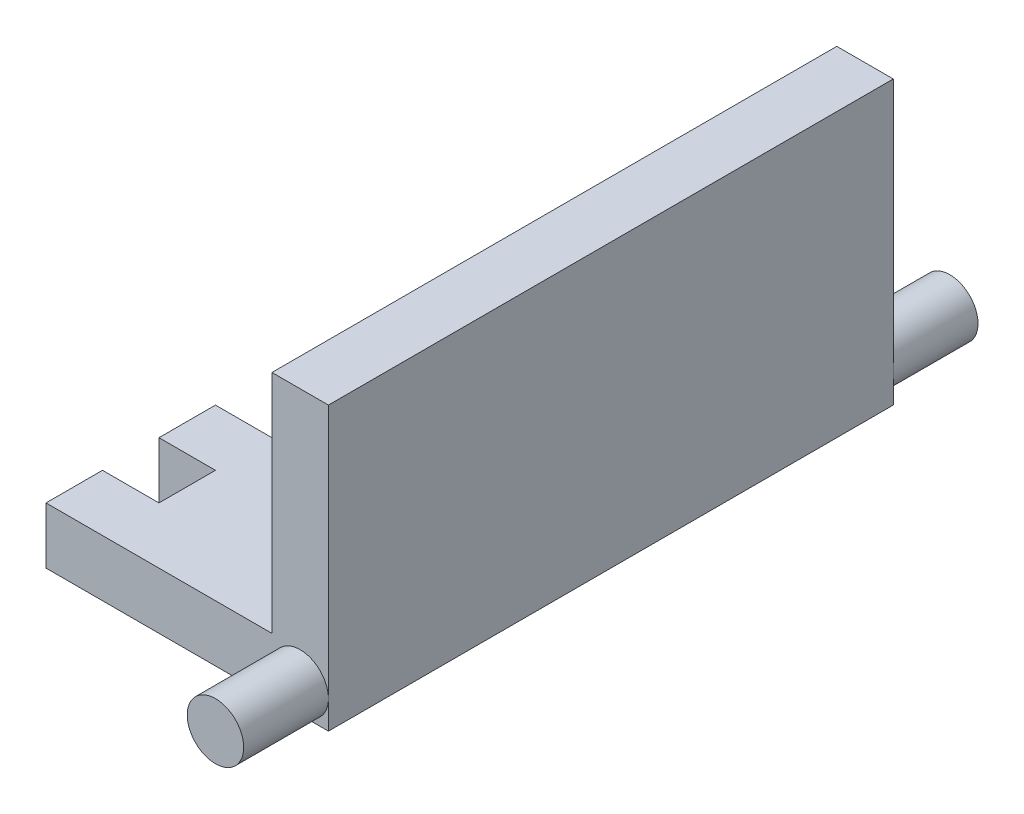
from build123d import *

# Parameters (mm, degrees)
ESQUISSE1_W                = 50
ESQUISSE1_H                = 10
BOSS_EXTRU_1_DEPTH         = 100
ESQUISSE2_R                = 5
BOSS_EXTRU_2_DEPTH         = 15
ESQUISSE3_R                = 5
BOSS_EXTRU_3_DEPTH         = 15
ESQUISSE4_W                = 10
ESQUISSE4_H                = 10
ENL_V_MAT_EXTRU_1_DEPTH    = 15
R_P_TITION_LIN_AIRE1_COUNT = 5
R_P_TITION_LIN_AIRE1_PITCH = 20
ESQUISSE5_W                = 10
ESQUISSE5_H                = 100
BOSS_EXTRU_4_DEPTH         = 40


with BuildPart() as part:
    # Esquisse1 → Boss.-Extru.1 (new body)
    with BuildSketch(Plane.XY):
        with Locations((-25, 5)):
            Rectangle(ESQUISSE1_W, ESQUISSE1_H)
    extrude(amount=BOSS_EXTRU_1_DEPTH)

    # Esquisse2 → Boss.-Extru.2 (add)
    with BuildSketch(Plane.XY.offset(100)):
        with Locations((-5, 5)):
            Circle(ESQUISSE2_R)
    extrude(amount=BOSS_EXTRU_2_DEPTH)

    # Esquisse3 → Boss.-Extru.3 (add)
    with BuildSketch(Plane(origin=(0, 0, 0), x_dir=(-1, 0, 0), z_dir=(0, 0, -1))):
        with Locations((5, 5)):
            Circle(ESQUISSE3_R)
    extrude(amount=BOSS_EXTRU_3_DEPTH)

    # Esquisse4 → Enlèv. mat.-Extru.1 (cut)
    with BuildSketch(Plane(origin=(0, 10, 0), x_dir=(1, 0, 0), z_dir=(0, 1, 0))):
        with Locations((-45, -5)):
            Rectangle(ESQUISSE4_W, ESQUISSE4_H)
    enl_v_mat_extru_1 = extrude(amount=-ENL_V_MAT_EXTRU_1_DEPTH, mode=Mode.SUBTRACT)

    # Répétition linéaire1: Enlèv. mat.-Extru.1 ×5
    with Locations(*[(0, 0, i * R_P_TITION_LIN_AIRE1_PITCH) for i in range(1, R_P_TITION_LIN_AIRE1_COUNT)]):
        add(enl_v_mat_extru_1, mode=Mode.SUBTRACT)

    # Esquisse5 → Boss.-Extru.4 (add)
    with BuildSketch(Plane(origin=(0, 10, 0), x_dir=(1, 0, 0), z_dir=(0, 1, 0))):
        with Locations((-5, -50)):
            Rectangle(ESQUISSE5_W, ESQUISSE5_H)
    extrude(amount=BOSS_EXTRU_4_DEPTH)


solid = part.part
